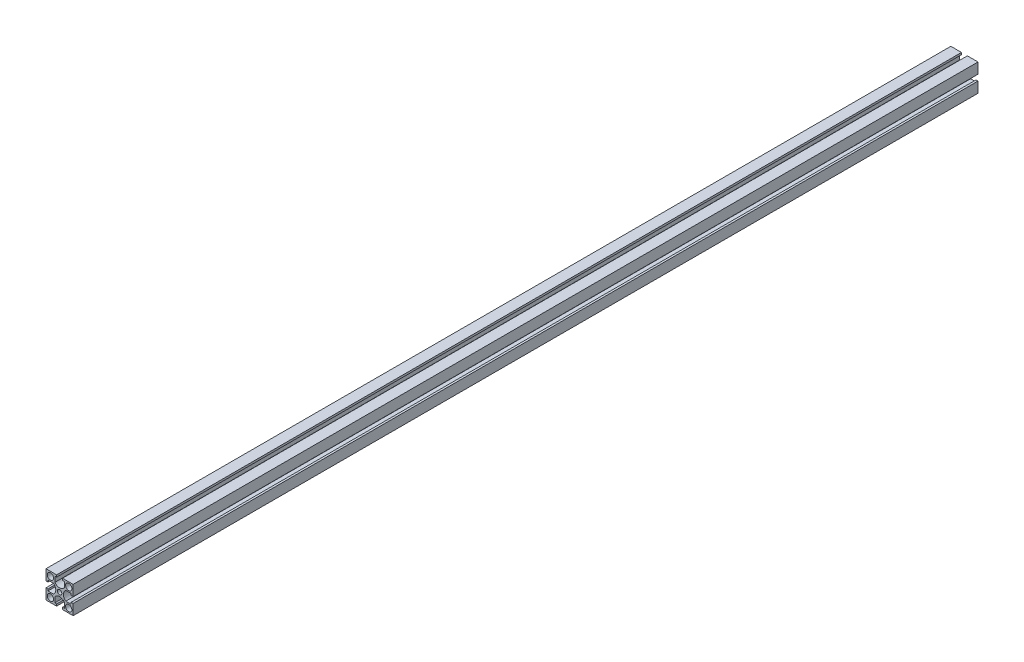
from build123d import *

# Parameters (mm, degrees)
SKETCH_1_R      = 3.5
SKETCH_1_R_2    = 2.5
EXTRUDE_1_DEPTH = 1000


with BuildPart() as part:
    # Эскиз1 → Бобышка-Вытянуть1 (new body)
    with BuildSketch(Plane.XY):
        with BuildLine():
            Line((-15, 5.2), (-15, 15))
            Line((-15, 15), (-5.2, 15))
            Line((-5.2, 15), (-3.25, 15))
            Line((-3.25, 15), (-3.25, 12.8))
            Line((-3.25, 12.8), (-5.2, 12.8))
            Line((-5.2, 12.8), (-5.2, 6.8))
            ThreePointArc((-5.2, 6.8), (0, 4.2), (5.2, 6.8))
            Line((5.2, 6.8), (5.2, 12.8))
            Line((5.2, 12.8), (3.25, 12.8))
            Line((3.25, 12.8), (3.25, 15))
            Line((3.25, 15), (5.2, 15))
            Line((5.2, 15), (15, 15))
            Line((15, 15), (15, 5.2))
            Line((15, 5.2), (15, 3.25))
            Line((15, 3.25), (12.8, 3.25))
            Line((12.8, 3.25), (12.8, 5.2))
            Line((12.8, 5.2), (6.8, 5.2))
            ThreePointArc((6.8, 5.2), (4.2, 0), (6.8, -5.2))
            Line((6.8, -5.2), (12.8, -5.2))
            Line((12.8, -5.2), (12.8, -3.25))
            Line((12.8, -3.25), (15, -3.25))
            Line((15, -3.25), (15, -5.2))
            Line((15, -5.2), (15, -15))
            Line((15, -15), (5.2, -15))
            Line((5.2, -15), (3.25, -15))
            Line((3.25, -15), (3.25, -12.8))
            Line((3.25, -12.8), (5.2, -12.8))
            Line((5.2, -12.8), (5.2, -6.8))
            ThreePointArc((5.2, -6.8), (0, -4.2), (-5.2, -6.8))
            Line((-5.2, -6.8), (-5.2, -12.8))
            Line((-5.2, -12.8), (-3.25, -12.8))
            Line((-3.25, -12.8), (-3.25, -15))
            Line((-3.25, -15), (-5.2, -15))
            Line((-5.2, -15), (-15, -15))
            Line((-15, -15), (-15, -5.2))
            Line((-15, -5.2), (-15, -3.25))
            Line((-15, -3.25), (-12.8, -3.25))
            Line((-12.8, -3.25), (-12.8, -5.2))
            Line((-12.8, -5.2), (-6.8, -5.2))
            ThreePointArc((-6.8, -5.2), (-4.2, 0), (-6.8, 5.2))
            Line((-6.8, 5.2), (-12.8, 5.2))
            Line((-12.8, 5.2), (-12.8, 3.25))
            Line((-12.8, 3.25), (-15, 3.25))
            Line((-15, 3.25), (-15, 5.2))
        make_face()
        with Locations((-10.1, 10.1)):
            Circle(SKETCH_1_R, mode=Mode.SUBTRACT)
        with Locations((10.1, 10.1)):
            Circle(SKETCH_1_R, mode=Mode.SUBTRACT)
        with Locations((-10.1, -10.1)):
            Circle(SKETCH_1_R, mode=Mode.SUBTRACT)
        with Locations((10.1, -10.1)):
            Circle(SKETCH_1_R, mode=Mode.SUBTRACT)
        Circle(SKETCH_1_R_2, mode=Mode.SUBTRACT)
    extrude(amount=EXTRUDE_1_DEPTH)


solid = part.part
